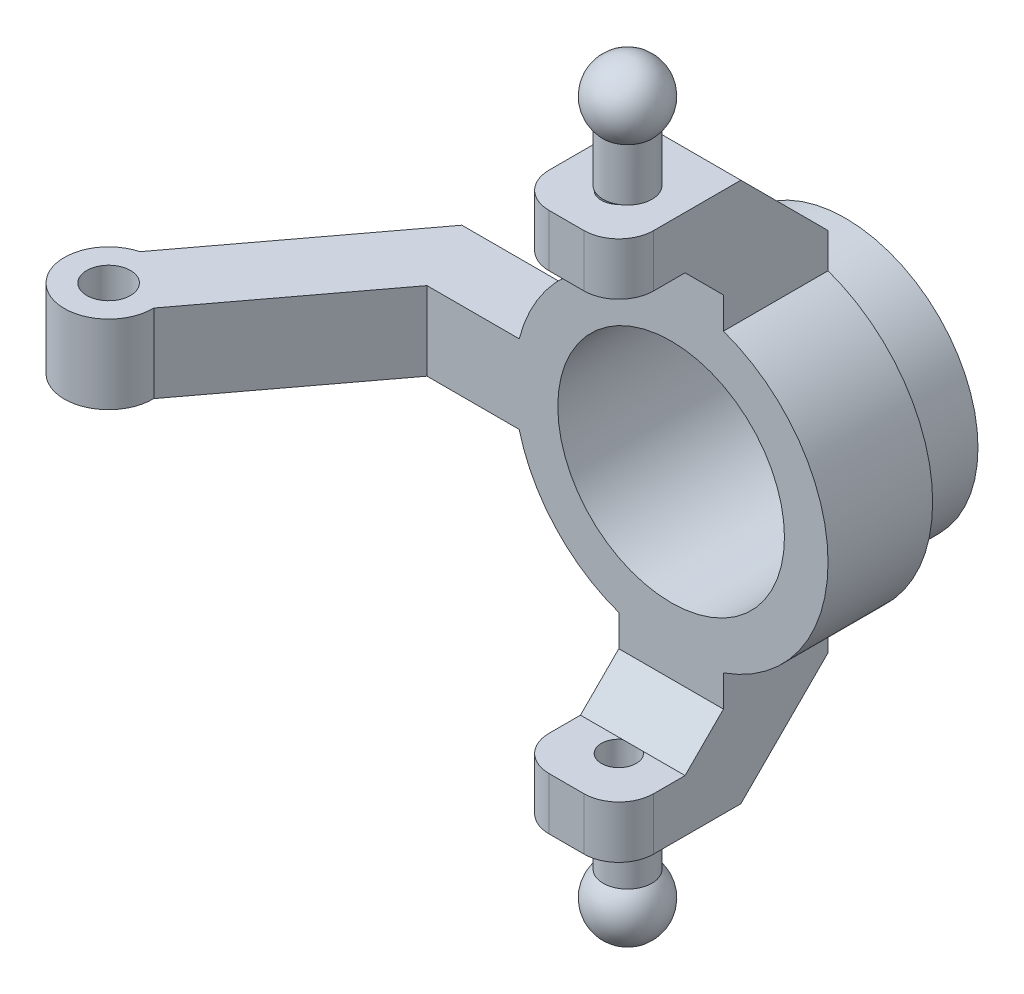
from build123d import *

# Parameters (mm, degrees)
CROQUIS1_R               = 45
CROQUIS1_R_2             = 32.5
SALIENTE_EXTRUIR1_DEPTH  = 30
SALIENTE_EXTRUIR2_DEPTH  = 30
CROQUIS3_W               = 60
CROQUIS3_H               = 15
SALIENTE_EXTRUIR3_DEPTH  = 15
REDONDEO1_R              = 10
REDONDEO2_R              = 15
CROQUIS4_R               = 5
CORTAR_EXTRUIR1_DEPTH    = 16
REDONDEO1_OF_SIMETR_A1_R = 10
REDONDEO2_OF_SIMETR_A1_R = 15
CROQUIS8_R               = 6.25
SALIENTE_EXTRUIR4_DEPTH  = 11.25
SALIENTE_EXTRUIR5_START  = 10
SALIENTE_EXTRUIR5_DEPTH  = 20
CORTAR_EXTRUIR2_DEPTH    = 61
CROQUIS12_R              = 38
CROQUIS12_R_2            = 32.5
SALIENTE_EXTRUIR7_DEPTH  = 20
SALIENTE_EXTRUIR9_DEPTH  = 30


with BuildPart() as part:
    # Croquis1 → Saliente-Extruir1 (new body)
    with BuildSketch(Plane.XY):
        Circle(CROQUIS1_R)
        Circle(CROQUIS1_R_2, mode=Mode.SUBTRACT)
    extrude(amount=SALIENTE_EXTRUIR1_DEPTH)

    # Croquis2 → Saliente-Extruir2 (add)
    with BuildSketch(Plane.XY):
        with BuildLine():
            Line((-15, -42.426406871), (-15, -77.426406871))
            Line((-15, -77.426406871), (15, -77.426406871))
            Line((15, -77.426406871), (15, -42.426406871))
            ThreePointArc((15, -42.426406871), (0, -45), (-15, -42.426406871))
        make_face()
    saliente_extruir2 = extrude(amount=SALIENTE_EXTRUIR2_DEPTH)

    # Croquis3 → Saliente-Extruir3 (add, symmetric)
    with BuildSketch(Plane(origin=(0, 0, 0), x_dir=(0, 0, -1), z_dir=(1, 0, 0))):
        with Locations((-30, -69.926406871)):
            Rectangle(CROQUIS3_W, CROQUIS3_H)
    saliente_extruir3 = extrude(amount=SALIENTE_EXTRUIR3_DEPTH, both=True)

    # Redondeo1
    redondeo1_edges = [part.edges().sort_by_distance(p)[0] for p in [
        (-15, -69.926406871, 60),
        (15, -69.926406871, 60),
    ]]
    fillet(redondeo1_edges, radius=REDONDEO1_R)

    # Redondeo2
    redondeo2_edges = [part.edges().sort_by_distance(p)[0] for p in [
        (0, -77.426406871, 0),
    ]]
    fillet(redondeo2_edges, radius=REDONDEO2_R)

    # Croquis4 → Cortar-Extruir1 (cut, through all)
    with BuildSketch(Plane(origin=(0, -62.426406871, 0), x_dir=(1, 0, 0), z_dir=(0, 1, 0))):
        with Locations((0, -45)):
            Circle(CROQUIS4_R)
    cortar_extruir1 = extrude(amount=-CORTAR_EXTRUIR1_DEPTH, mode=Mode.SUBTRACT)

    # Simetría1: Saliente-Extruir2, Saliente-Extruir3, Cortar-Extruir1 across plane
    add(saliente_extruir2.mirror(Plane.ZX))
    add(saliente_extruir3.mirror(Plane.ZX))
    add(cortar_extruir1.mirror(Plane.ZX), mode=Mode.SUBTRACT)

    # Redondeo1 of Simetría1
    redondeo1_of_simetr_a1_edges = [part.edges().sort_by_distance(p)[0] for p in [
        (-15, 69.926406871, 60),
        (15, 69.926406871, 60),
    ]]
    fillet(redondeo1_of_simetr_a1_edges, radius=REDONDEO1_OF_SIMETR_A1_R)

    # Redondeo2 of Simetría1
    redondeo2_of_simetr_a1_edges = [part.edges().sort_by_distance(p)[0] for p in [
        (0, 77.426406871, 0),
    ]]
    fillet(redondeo2_of_simetr_a1_edges, radius=REDONDEO2_OF_SIMETR_A1_R)



with BuildPart() as body_2:
    # Croquis8 → Saliente-Extruir4 (new body, symmetric)
    with BuildSketch(Plane(origin=(0, 0, 0), x_dir=(1, 0, 0), z_dir=(0, 1, 0))):
        with BuildLine():
            Line((-45, -30), (-70.006566453, -30))
            Line((-70.006566453, -30), (-103.60103907, -74.743636588))
            ThreePointArc((-103.60103907, -74.743636588), (-123.92378818, -85.155995163), (-119.59473224, -62.735232082))
            Line((-119.59473224, -62.735232082), (-80, -10))
            Line((-80, -10), (-45, -10))
            Line((-45, -10), (-45, -30))
        make_face()
        with Locations((-116.298451318, -75)):
            Circle(CROQUIS8_R, mode=Mode.SUBTRACT)
    extrude(amount=SALIENTE_EXTRUIR4_DEPTH, both=True)


with BuildPart() as part_1:
    add(part.part)

    add(body_2.part)  # Saliente-Extruir5 merges body 2
    # Croquis9 → Saliente-Extruir5 (add)
    with BuildSketch(Plane.XY.offset(SALIENTE_EXTRUIR5_START)):
        with BuildLine():
            Line((-43.571062645, 11.25), (-45, 11.25))
            Line((-45, 11.25), (-45, 0))
            ThreePointArc((-45, 0), (-44.641336332, 5.670193162), (-43.571062645, 11.25))
        make_face()
        with BuildLine():
            ThreePointArc((-43.571062645, -11.25), (-44.641336332, -5.670193162), (-45, 0))
            Line((-45, 0), (-45, -11.25))
            Line((-45, -11.25), (-43.571062645, -11.25))
        make_face()
    extrude(amount=SALIENTE_EXTRUIR5_DEPTH)

    # Croquis11 → Cortar-Extruir2 (cut, through all)
    with BuildSketch(Plane.ZY.offset(15)):
        with BuildLine():
            Line((0, 62.426406871), (0, 52.426406871))
            Line((0, 52.426406871), (25, 77.426406871))
            Line((25, 77.426406871), (15, 77.426406871))
            ThreePointArc((15, 77.426406871), (4.393398282, 73.033008589), (0, 62.426406871))
        make_face()
    cortar_extruir2 = extrude(amount=-CORTAR_EXTRUIR2_DEPTH, mode=Mode.SUBTRACT)

    # Simetría2: Cortar-Extruir2 across plane
    add(cortar_extruir2.mirror(Plane.ZX), mode=Mode.SUBTRACT)

    # Croquis12 → Saliente-Extruir7 (add)
    with BuildSketch(Plane(origin=(0, 0, 0), x_dir=(-1, 0, 0), z_dir=(0, 0, -1))):
        Circle(CROQUIS12_R)
        Circle(CROQUIS12_R_2, mode=Mode.SUBTRACT)
    extrude(amount=SALIENTE_EXTRUIR7_DEPTH)

    # Croquis13 → Saliente-Extruir9 (add)
    with BuildSketch(Plane.ZY.offset(15)):
        Polygon((30, 62.426406871), (30, 51.426406871), (41, 62.426406871), align=None)
    saliente_extruir9 = extrude(amount=-SALIENTE_EXTRUIR9_DEPTH)

    # Simetría3: Saliente-Extruir9 across plane
    add(saliente_extruir9.mirror(Plane.ZX))

    # Croquis14 → Revolución1 (revolve)
    with BuildSketch(Plane(origin=(0, 0, 0), x_dir=(0, 0, -1), z_dir=(1, 0, 0))):
        with BuildLine():
            Line((-49.5, 77.426406871), (-49.5, 92.426406871))
            ThreePointArc((-49.5, 92.426406871), (-51.757815193, 103.348424917), (-42.5, 109.5678353))
            Line((-42.5, 109.5678353), (-42.5, 77.426406871))
            Line((-42.5, 77.426406871), (-49.5, 77.426406871))
        make_face()
    revoluci_n1 = revolve(axis=Axis((0, 77.426406871, 42.5), (0, 1, 0)))

    # Simetría4: Revolución1 across plane
    add(revoluci_n1.mirror(Plane.ZX))


solid = part_1.part
